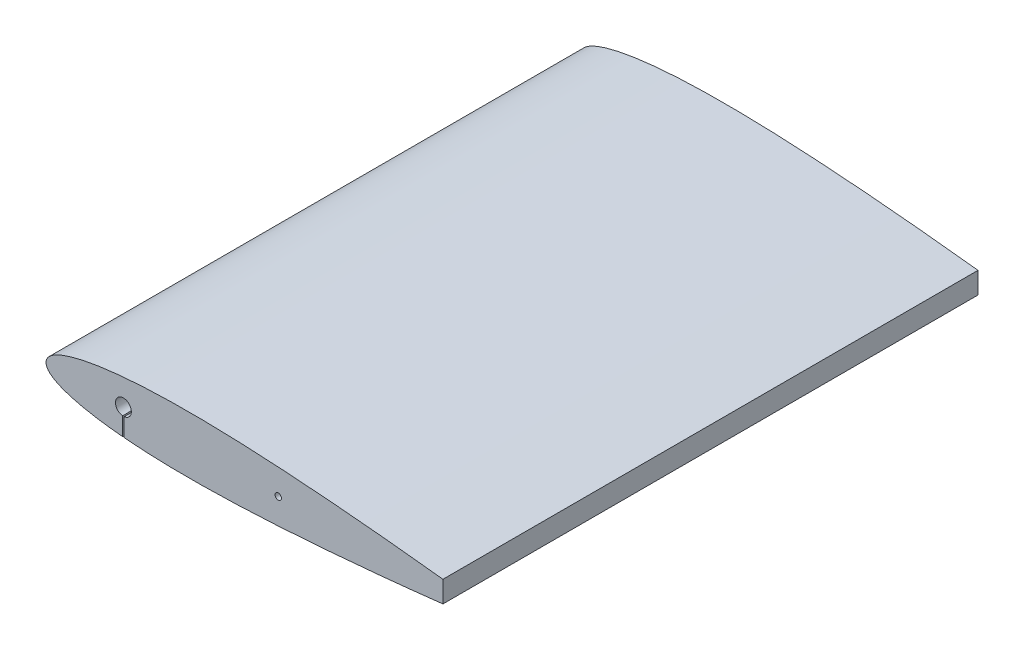
from build123d import *

# Parameters (mm, degrees)
BOSS_EXTRUDE1_DEPTH      = 168.5
SKETCH7_R                = 5
CUT_EXTRUDE14_DEPTH      = 345.552432504
CUT_EXTRUDE14_DEPTH_BACK = 345.552432504
SKETCH8_W                = 44.16
SKETCH8_H                = 34.63
CUT_EXTRUDE8_DEPTH       = 345.784581051
SKETCH10_W               = 50
SKETCH10_H               = 337
CUT_EXTRUDE9_DEPTH       = 345.552432504
CUT_EXTRUDE9_DEPTH_BACK  = 345.552432504
CUT_EXTRUDE11_START      = -168.5
SKETCH13_R               = 2
CUT_EXTRUDE11_DEPTH      = 20
CUT_EXTRUDE12_START      = 168.5
SKETCH14_R               = 2
CUT_EXTRUDE12_DEPTH      = 20
SKETCH15_W               = 1
SKETCH15_H               = 18.003573168
CUT_EXTRUDE13_DEPTH      = 303.020493898
CUT_EXTRUDE13_DEPTH_BACK = 303.020493898


with BuildPart() as part:
    # Sketch5 → Boss-Extrude1 (new, symmetric)
    with BuildSketch(Plane.XY):
        with BuildLine():
            Line((300, 0.378000085), (300, -0.378000086))
            add(Edge.make_bspline(
                [(300, 0.378000085), (299.270406258, 0.47944593), (297.234666467, 0.762503926), (293.659648722, 1.25767379), (289.112409325, 1.874242867), (284.080813047, 2.544518017), (278.752039398, 3.23812305), (273.265892957, 3.934947328), (267.705948145, 4.629020993), (262.114554424, 5.313070312), (256.508339042, 5.982193169), (250.891727853, 6.637992315), (245.269544548, 7.281780887), (239.647331656, 7.912234558), (234.025115138, 8.52699398), (228.399071658, 9.126231834), (222.768240123, 9.713079809), (217.135901993, 10.287462143), (211.505390076, 10.846943545), (205.877598449, 11.391645411), (200.251489743, 11.920887328), (194.626396629, 12.434619899), (189.002771954, 12.931914743), (183.381504479, 13.413100624), (177.763197883, 13.876379849), (172.148272526, 14.321240442), (166.537499181, 14.747824264), (160.931704642, 15.154231582), (155.331676028, 15.539104381), (149.737504253, 15.902653171), (144.148652919, 16.241849803), (138.565642978, 16.557424303), (132.990821912, 16.847401377), (127.427400287, 17.11021556), (121.877579225, 17.343895652), (116.340716908, 17.545260793), (110.81543346, 17.712683138), (105.301229225, 17.844501986), (99.800524694, 17.940095883), (94.317389178, 17.996594521), (88.855716162, 18.010128544), (83.418598836, 17.979237919), (78.008430461, 17.899164774), (72.628403778, 17.767037818), (67.282685946, 17.579417922), (61.977310891, 17.331519421), (56.72063582, 17.021036513), (51.525118947, 16.640961845), (46.408145083, 16.190192264), (41.394117392, 15.661672653), (36.515611307, 15.053967199), (31.818948595, 14.365626864), (27.366102973, 13.60347877), (23.235155161, 12.782586344), (19.502578811, 11.920253456), (16.218207008, 11.044600302), (13.389120989, 10.175078564), (10.984863761, 9.333500833), (8.961495446, 8.522064815), (7.267225637, 7.746977759), (5.845985727, 7.010627212), (4.647644075, 6.300635462), (3.62816801, 5.60651494), (2.751841757, 4.926636369), (2.006189751, 4.249918223), (1.390518388, 3.570260302), (0.900932575, 2.890942908), (0.52920759, 2.220219777), (0.260411531, 1.566459291), (0.085644609, 0.931036139), (-0.003577313, 0.308981085), (-0.003577313, -0.308981085), (0.085644609, -0.931036139), (0.260411531, -1.566459291), (0.52920759, -2.220219777), (0.900932575, -2.890942908), (1.390518388, -3.570260302), (2.006189751, -4.249918223), (2.751841757, -4.926636369), (3.62816801, -5.60651494), (4.647644075, -6.300635462), (5.845985727, -7.010627213), (7.267225637, -7.746977757), (8.961495444, -8.522064829), (10.984863772, -9.333500769), (13.389120938, -10.175078867), (16.218207245, -11.044598882), (19.502577721, -11.920259984), (23.235160006, -12.782557313), (27.366065703, -13.603599247), (31.819014163, -14.365116623), (36.515574857, -15.054109513), (41.394123531, -15.661632441), (46.408143388, -16.190203367), (51.525119411, -16.640958803), (56.720635693, -17.021037342), (61.977310926, -17.331519196), (67.282685937, -17.579417983), (72.628403781, -17.767037802), (78.00843046, -17.899164779), (83.418598837, -17.979237918), (88.855716162, -18.010128545), (94.317389178, -17.996594522), (99.800524694, -17.940095883), (105.301229225, -17.844501987), (110.81543346, -17.712683139), (116.340716908, -17.545260794), (121.877579225, -17.343895653), (127.427400287, -17.110215561), (132.990821912, -16.847401378), (138.565642978, -16.557424303), (144.148652919, -16.241849804), (149.737504253, -15.902653172), (155.331676028, -15.539104382), (160.931704642, -15.154231583), (166.537499181, -14.747824265), (172.148272526, -14.321240443), (177.763197883, -13.87637985), (183.381504479, -13.413100625), (189.002771954, -12.931914744), (194.626396629, -12.4346199), (200.251489743, -11.920887329), (205.877598449, -11.391645412), (211.505390076, -10.846943545), (217.135901993, -10.287462144), (222.768240123, -9.71307981), (228.399071658, -9.126231835), (234.025115138, -8.526993981), (239.647331656, -7.912234559), (245.269544548, -7.281780888), (250.891727853, -6.637992316), (256.508339042, -5.98219317), (262.114554424, -5.313070313), (267.705948145, -4.629020994), (273.265892957, -3.934947329), (278.752039398, -3.238123051), (284.080813047, -2.544518018), (289.112409325, -1.874242868), (293.659648722, -1.257673792), (297.234666467, -0.762503927), (299.270406258, -0.479445931), (300, -0.378000086)],
                knots=[0, 0, 0, 0, 0.003612221, 0.010078953, 0.017698618, 0.026115111, 0.034970966, 0.04405038, 0.05323433, 0.06244757, 0.071673993, 0.080921319, 0.090177538, 0.099424342, 0.108664441, 0.117912199, 0.127169502, 0.136426595, 0.145675426, 0.154916495, 0.164153237, 0.173386649, 0.182615736, 0.191838089, 0.201053134, 0.210260393, 0.219458942, 0.228646747, 0.237822316, 0.246985224, 0.256137384, 0.265279416, 0.27440695, 0.283512193, 0.292591781, 0.301646285, 0.310681793, 0.319699068, 0.32869452, 0.33766016, 0.346588583, 0.355477412, 0.364322937, 0.373121614, 0.381867635, 0.390553005, 0.399166026, 0.407689628, 0.416098119, 0.424354887, 0.432412429, 0.440204728, 0.447630505, 0.454563638, 0.460855379, 0.466413319, 0.47122861, 0.475365774, 0.47890126, 0.481915077, 0.484498872, 0.486747127, 0.488741252, 0.490543179, 0.492182104, 0.493672831, 0.495031908, 0.49627906, 0.497424737, 0.498490166, 0.499502758, 0.500497254, 0.501509846, 0.502575275, 0.503720952, 0.504968104, 0.506327181, 0.507817908, 0.509456832, 0.51125876, 0.513252884, 0.51550114, 0.518084934, 0.521098752, 0.524634237, 0.528771401, 0.533586692, 0.539144632, 0.545436374, 0.552369506, 0.5597952, 0.567587571, 0.575645113, 0.583901881, 0.592310372, 0.600833974, 0.609446995, 0.618132365, 0.626878386, 0.635677063, 0.644522588, 0.653411417, 0.66233984, 0.67130548, 0.680300932, 0.689318207, 0.698353715, 0.707408219, 0.716487807, 0.72559305, 0.734720584, 0.743862616, 0.753014776, 0.762177684, 0.771353253, 0.780541058, 0.789739607, 0.798946866, 0.808161911, 0.817384264, 0.826613351, 0.835846763, 0.845083505, 0.854324574, 0.863573405, 0.872830498, 0.882087801, 0.891335559, 0.900575658, 0.909822462, 0.919078681, 0.928326007, 0.93755243, 0.94676567, 0.95594962, 0.965029034, 0.973884889, 0.982301382, 0.989921047, 0.996387779, 1, 1, 1, 1], degree=3))
        make_face()
    extrude(amount=BOSS_EXTRUDE1_DEPTH, both=True)

    # Sketch7 → Cut-Extrude14 (cut, two sides)
    with BuildSketch(Plane.XY) as cut_extrude14_sk:
        with Locations((48.75, 0)):
            Circle(SKETCH7_R)
    extrude(amount=CUT_EXTRUDE14_DEPTH, mode=Mode.SUBTRACT)
    extrude(cut_extrude14_sk.sketch, amount=-CUT_EXTRUDE14_DEPTH_BACK, mode=Mode.SUBTRACT)

    # Sketch8 → Cut-Extrude8 (cut, through all)
    with BuildSketch(Plane(origin=(0, -4, 0), x_dir=(1, 0, 0), z_dir=(0, 1, 0))):
        with Locations((207.92, 23.495)):
            Rectangle(SKETCH8_W, SKETCH8_H)
    extrude(amount=-CUT_EXTRUDE8_DEPTH, mode=Mode.SUBTRACT)

    # Sketch10 → Cut-Extrude9 (cut, two sides)
    with BuildSketch(Plane(origin=(0, 0, 0), x_dir=(1, 0, 0), z_dir=(0, 1, 0))) as cut_extrude9_sk:
        with Locations((275, 0)):
            Rectangle(SKETCH10_W, SKETCH10_H)
    extrude(amount=CUT_EXTRUDE9_DEPTH, mode=Mode.SUBTRACT)
    extrude(cut_extrude9_sk.sketch, amount=-CUT_EXTRUDE9_DEPTH_BACK, mode=Mode.SUBTRACT)

    # Sketch13 → Cut-Extrude11 (cut)
    with BuildSketch(Plane.XY.offset(CUT_EXTRUDE11_START)):
        with Locations(Location((146.25, 0, 0), (0, 0, 180))):
            Circle(SKETCH13_R)
    extrude(amount=CUT_EXTRUDE11_DEPTH, mode=Mode.SUBTRACT)

    # Sketch14 → Cut-Extrude12 (cut)
    with BuildSketch(Plane.XY.offset(CUT_EXTRUDE12_START)):
        with Locations(Location((146.25, 0, 0), (0, 0, 180))):
            Circle(SKETCH14_R)
    extrude(amount=-CUT_EXTRUDE12_DEPTH, mode=Mode.SUBTRACT)

    # Sketch15 → Cut-Extrude13 (cut, two sides)
    with BuildSketch(Plane.XY) as cut_extrude13_sk:
        with Locations((48.75, -9.001786584)):
            Rectangle(SKETCH15_W, SKETCH15_H)
    extrude(amount=CUT_EXTRUDE13_DEPTH, mode=Mode.SUBTRACT)
    extrude(cut_extrude13_sk.sketch, amount=-CUT_EXTRUDE13_DEPTH_BACK, mode=Mode.SUBTRACT)


solid = part.part
